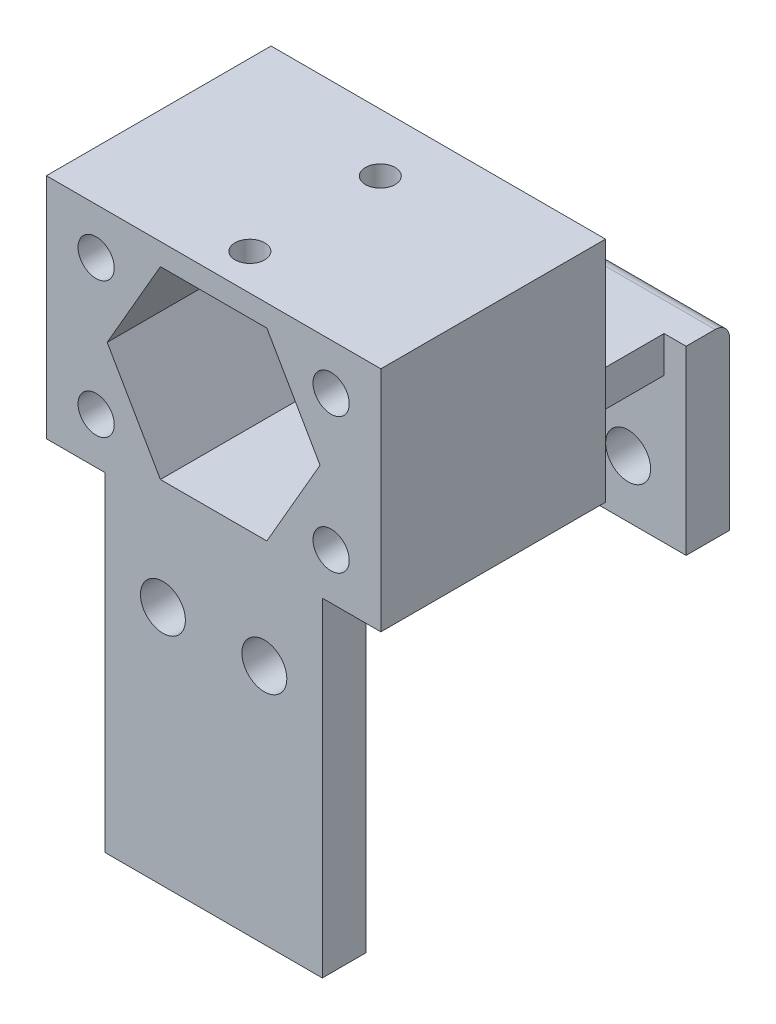
from build123d import *

# Parameters (mm, degrees)
BOSS_EXTRUDE1_DEPTH     = 14
SKETCH2_R               = 4.75
BOSS_EXTRUDE2_DEPTH     = 1.5
SKETCH8_R               = 1.55
BOSS_EXTRUDE3_DEPTH     = 3
BOSS_EXTRUDE4_START     = -25.1
SKETCH8_2_R             = 1.55
BOSS_EXTRUDE4_DEPTH     = 3
BOSS_EXTRUDE6_DEPTH     = 12.6
M2_5_TAPPED_HOLE1_D     = 2.05
M2_5_TAPPED_HOLE1_DEPTH = 1.5
BOSS_EXTRUDE8_DEPTH     = 5
BOSS_EXTRUDE9_REACH     = 17.72
SKETCH22_W              = 4.537973116
SKETCH22_H              = 2
FILLET2_R               = 1
BOSS_EXTRUDE11_DEPTH    = 10.5
M3_TAPPED_HOLE2_D       = 2.5
M3_TAPPED_HOLE2_DEPTH   = 15.5
M3_TAPPED_HOLE2_TIP     = 0.751075774
BOSS_EXTRUDE12_DEPTH    = 9.6
SKETCH26_W              = 15
SKETCH26_H              = 3
BOSS_EXTRUDE13_DEPTH    = 12.7


with BuildPart() as part:
    # Sketch1 → Boss-Extrude1 (new body)
    with BuildSketch(Plane.XY):
        Polygon((9.075946232, 0), (4.537973116, 7.86), (-4.537973116, 7.86), (-9.075946232, 0), (-4.537973116, -7.86), (4.537973116, -7.86), align=None)
        Polygon((7.343895424, 0), (3.671947712, 6.36), (-3.671947712, 6.36), (-7.343895424, 0), (-3.671947712, -6.36), (3.671947712, -6.36), align=None, mode=Mode.SUBTRACT)
    extrude(amount=BOSS_EXTRUDE1_DEPTH)

    # Sketch2 → Boss-Extrude2 (add)
    with BuildSketch(Plane(origin=(0, 0, 0), x_dir=(-1, 0, 0), z_dir=(0, 0, -1))):
        Polygon((9.075946232, 0), (4.537973116, 7.86), (-4.537973116, 7.86), (-9.075946232, 0), (-4.537973116, -7.86), (4.537973116, -7.86), align=None)
        Circle(SKETCH2_R, mode=Mode.SUBTRACT)
    extrude(amount=BOSS_EXTRUDE2_DEPTH)

    # Sketch8 → Boss-Extrude3 (add)
    with BuildSketch(Plane.XY.offset(14)):
        Polygon((-7.5, -17.86), (7.5, -17.86), (7.5, -7.86), (9.075946232, -7.86), (9.075946232, 0), (4.537973116, -7.86), (-4.537973116, -7.86), (-9.075946232, 0), (-9.075946232, -7.86), (-7.5, -7.86), align=None)
        with Locations((-3.5, -13.91)):
            Circle(SKETCH8_R, mode=Mode.SUBTRACT)
        with Locations((3.5, -13.91)):
            Circle(SKETCH8_R, mode=Mode.SUBTRACT)
    extrude(amount=-BOSS_EXTRUDE3_DEPTH)



with BuildPart() as body_2:
    # Sketch8_2 → Boss-Extrude4 (new body)
    with BuildSketch(Plane.XY.offset(14).offset(BOSS_EXTRUDE4_START)):
        Polygon((-7.5, -7.86), (-7.5, -17.86), (7.5, -17.86), (7.5, -7.86), (7.5, -5.36), (5.981348789, -5.36), (4.537973116, -7.86), (-4.537973116, -7.86), (-5.981348789, -5.36), (-7.5, -5.36), align=None)
        with Locations((-3.5, -13.91)):
            Circle(SKETCH8_2_R, mode=Mode.SUBTRACT)
        with Locations((3.5, -13.91)):
            Circle(SKETCH8_2_R, mode=Mode.SUBTRACT)
    extrude(amount=-BOSS_EXTRUDE4_DEPTH)


with BuildPart() as part_1:
    add(part.part)

    add(body_2.part)  # Boss-Extrude6 merges body 2
    # Sketch9 → Boss-Extrude6 (add)
    with BuildSketch(Plane(origin=(0, 0, -1.5), x_dir=(-1, 0, 0), z_dir=(0, 0, -1))):
        Polygon((-5.981348789, -5.36), (5.981348789, -5.36), (4.537973116, -7.86), (-4.537973116, -7.86), align=None)
    extrude(amount=BOSS_EXTRUDE6_DEPTH)

    # M2.5 Tapped Hole1
    with Locations(Plane(origin=(0, 7.86, 0), x_dir=(1, 0, 0), z_dir=(0, 1, 0))):
        with Locations((0, -2.5), (0, -11.5)):
            Hole(M2_5_TAPPED_HOLE1_D / 2, depth=M2_5_TAPPED_HOLE1_DEPTH)

    # Sketch14 → Boss-Extrude8 (add)
    with BuildSketch(Plane.XY.offset(14)):
        Polygon((-4.537973116, 7.86), (-11.537973116, 7.86), (-11.537973116, -7.86), (-9.075946232, -7.86), (-9.075946232, 0), align=None)
        Polygon((9.075946232, -7.86), (9.075946232, 0), (4.537973116, 7.86), (11.537973116, 7.86), (11.537973116, -7.86), align=None)
    extrude(amount=-BOSS_EXTRUDE8_DEPTH)

    # Sketch22 → Boss-Extrude9 (add, up to next)
    with BuildSketch(Plane.XZ.offset(7.86), mode=Mode.PRIVATE) as boss_extrude9_sk1:
        with Locations((-6.806959674, 10)):
            Rectangle(SKETCH22_W, SKETCH22_H)
    boss_extrude9_tool1 = extrude(boss_extrude9_sk1.sketch, amount=-BOSS_EXTRUDE9_REACH, mode=Mode.PRIVATE) - part_1.part
    add(boss_extrude9_tool1.solids().sort_by_distance((-6.80696, -7.86, 10))[0])
    # Sketch22 → Boss-Extrude9 (add, up to next)
    with BuildSketch(Plane.XZ.offset(7.86), mode=Mode.PRIVATE) as boss_extrude9_sk2:
        with Locations((6.806959674, 10)):
            Rectangle(SKETCH22_W, SKETCH22_H)
    boss_extrude9_tool2 = extrude(boss_extrude9_sk2.sketch, amount=-BOSS_EXTRUDE9_REACH, mode=Mode.PRIVATE) - part_1.part
    add(boss_extrude9_tool2.solids().sort_by_distance((6.80696, -7.86, 10))[0])

    # Fillet2
    fillet2_edges = [part_1.edges().sort_by_distance(p)[0] for p in [
        (0, -5.36, -14.1),
    ]]
    fillet(fillet2_edges, radius=FILLET2_R)

    # Sketch24 → Boss-Extrude11 (add)
    with BuildSketch(Plane(origin=(0, 0, 9), x_dir=(-1, 0, 0), z_dir=(0, 0, -1))):
        Polygon((-11.537973116, -7.86), (-4.537973116, -7.86), (-9.075946232, 0), (-4.537973116, 7.86), (-11.537973116, 7.86), align=None)
        Polygon((4.537973116, 7.86), (9.075946232, 0), (4.537973116, -7.86), (11.537973116, -7.86), (11.537973116, 7.86), align=None)
    extrude(amount=BOSS_EXTRUDE11_DEPTH)

    # M3 Tapped Hole2
    with Locations(Plane.XY.offset(14)):
        with Locations((-8.105997779, 4.68), (-8.105997779, -4.68), (8.105997779, 4.68), (8.105997779, -4.68)):
            Hole(M3_TAPPED_HOLE2_D / 2, depth=M3_TAPPED_HOLE2_DEPTH)
            with Locations((0, 0, -(M3_TAPPED_HOLE2_DEPTH + M3_TAPPED_HOLE2_TIP / 2))):  # 118° drill point
                Cone(0, M3_TAPPED_HOLE2_D / 2, M3_TAPPED_HOLE2_TIP, mode=Mode.SUBTRACT)

    # Sketch25 → Boss-Extrude12 (add)
    with BuildSketch(Plane(origin=(0, 0, -1.5), x_dir=(-1, 0, 0), z_dir=(0, 0, -1))):
        Polygon((-5.981348789, -5.36), (-5.981348789, -7.86), (-4.537973116, -7.86), align=None)
    extrude(amount=BOSS_EXTRUDE12_DEPTH)

    # Sketch26 → Boss-Extrude13 (add)
    with BuildSketch(Plane.XZ.offset(17.86)):
        with Locations((0, 12.5)):
            Rectangle(SKETCH26_W, SKETCH26_H)
    extrude(amount=BOSS_EXTRUDE13_DEPTH)


solid = part_1.part
